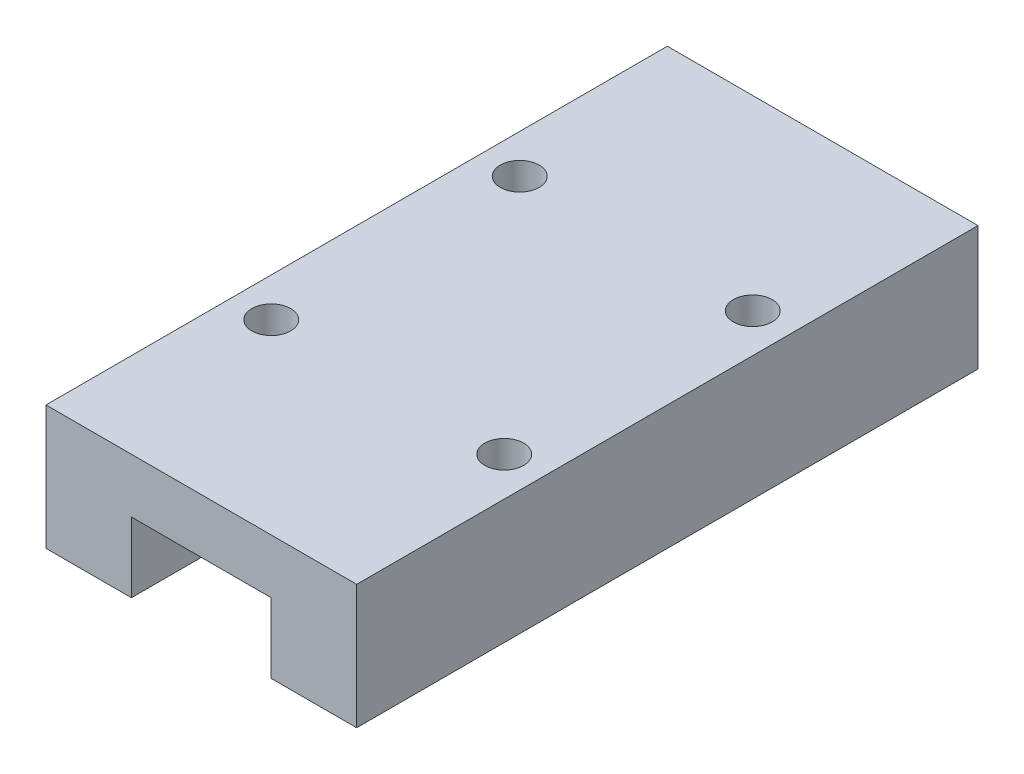
from build123d import *

# Parameters (mm, degrees)
BOSS_EXTRUDE1_DEPTH       = 40
M3X0_5_TAPPED_HOLE1_D     = 2.5
M3X0_5_TAPPED_HOLE1_DEPTH = 6
M3X0_5_TAPPED_HOLE1_TIP   = 0.751075774


with BuildPart() as part:
    # Sketch2 → Boss-Extrude1 (new body)
    with BuildSketch(Plane.XY):
        Polygon((0, 0), (0, 8), (20, 8), (20, 0), (14.5, 0), (14.5, 4.5), (5.5, 4.5), (5.5, 0), align=None)
    extrude(amount=BOSS_EXTRUDE1_DEPTH)

    # M3x0.5 Tapped Hole1
    with Locations(Plane(origin=(0, 8, 0), x_dir=(1, 0, 0), z_dir=(0, 1, 0))):
        with Locations((2.5, -28), (2.5, -12), (17.5, -28), (17.5, -12)):
            Hole(M3X0_5_TAPPED_HOLE1_D / 2, depth=M3X0_5_TAPPED_HOLE1_DEPTH)
            with Locations((0, 0, -(M3X0_5_TAPPED_HOLE1_DEPTH + M3X0_5_TAPPED_HOLE1_TIP / 2))):  # 118° drill point
                Cone(0, M3X0_5_TAPPED_HOLE1_D / 2, M3X0_5_TAPPED_HOLE1_TIP, mode=Mode.SUBTRACT)


solid = part.part
